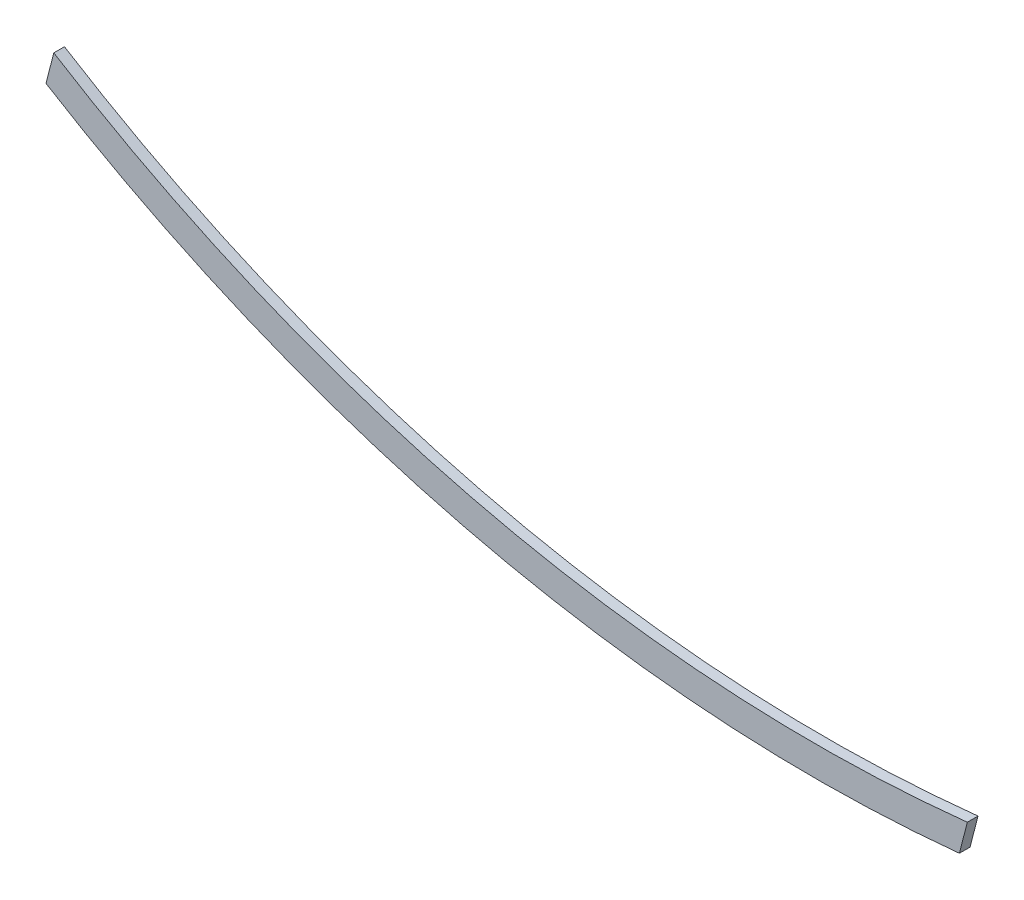
from build123d import *

# Parameters (mm, degrees)
BOSS_EXTRUDE1_DEPTH = 50


with BuildPart() as part:
    # Sketch1 → Boss-Extrude1 (new body)
    with BuildSketch(Plane.XY):
        with BuildLine():
            Line((105.481064022, -60.600500284), (142.520881473, 83.95768345))
            ThreePointArc((142.520881473, 83.95768345), (68.350790111, 76.443542351), (-5.897952721, 69.751087115))
            ThreePointArc((-5.897952721, 69.751087115), (-2066.112263244, 213.410002875), (-3985.865660325, 974.769171568))
            ThreePointArc((-3985.865660325, 974.769171568), (-4060.427881722, 1019.260195983), (-4134.410165272, 1064.709044526))
            Line((-4134.410165272, 1064.709044526), (-4170.821020404, 922.605561078))
            ThreePointArc((-4170.821020404, 922.605561078), (-4113.989335475, 888.069649409), (-4056.826147178, 854.085248423))
            ThreePointArc((-4056.826147178, 854.085248423), (-2097.154872136, 76.894961824), (5.897952721, -69.751087115))
            ThreePointArc((5.897952721, -69.751087115), (55.706151401, -65.356914833), (105.481064022, -60.600500284))
        make_face()
    extrude(amount=BOSS_EXTRUDE1_DEPTH)


solid = part.part
